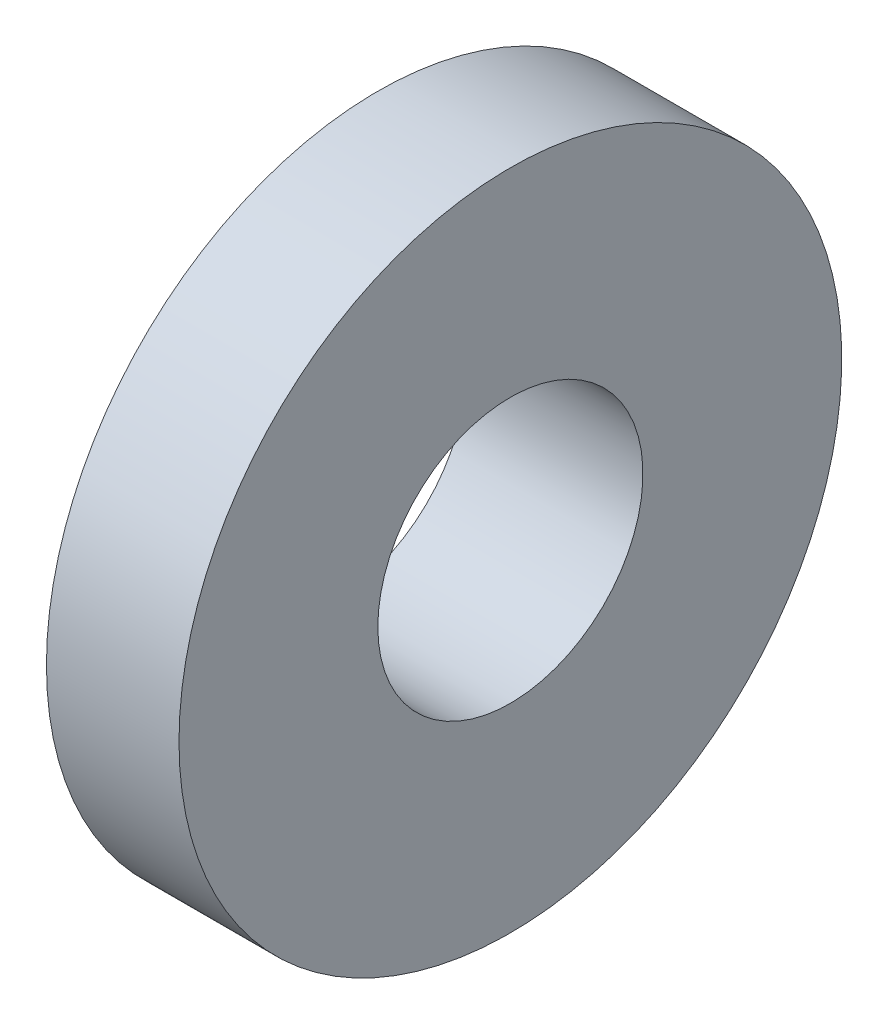
from build123d import *

# Parameters (mm, degrees)
SCALE1_SCALE = 1.7


with BuildPart() as part:
    # Sketch1 → Revolve1 (revolve)
    with BuildSketch(Plane.XY):
        Polygon((0, 1.5), (0, 2.5), (0.5, 2.5), (0.5, 3.75), (2, 3.75), (2, 1.5), align=None)
    revolve(axis=Axis((0, 0, 0), (1, 0, 0)))


with BuildPart() as part_1:
    # Scale1: scaled about (1.148573693, 0, 0)
    add(part.part.scale(SCALE1_SCALE).moved(Location((-0.804001585, 0, 0))))


solid = part_1.part
